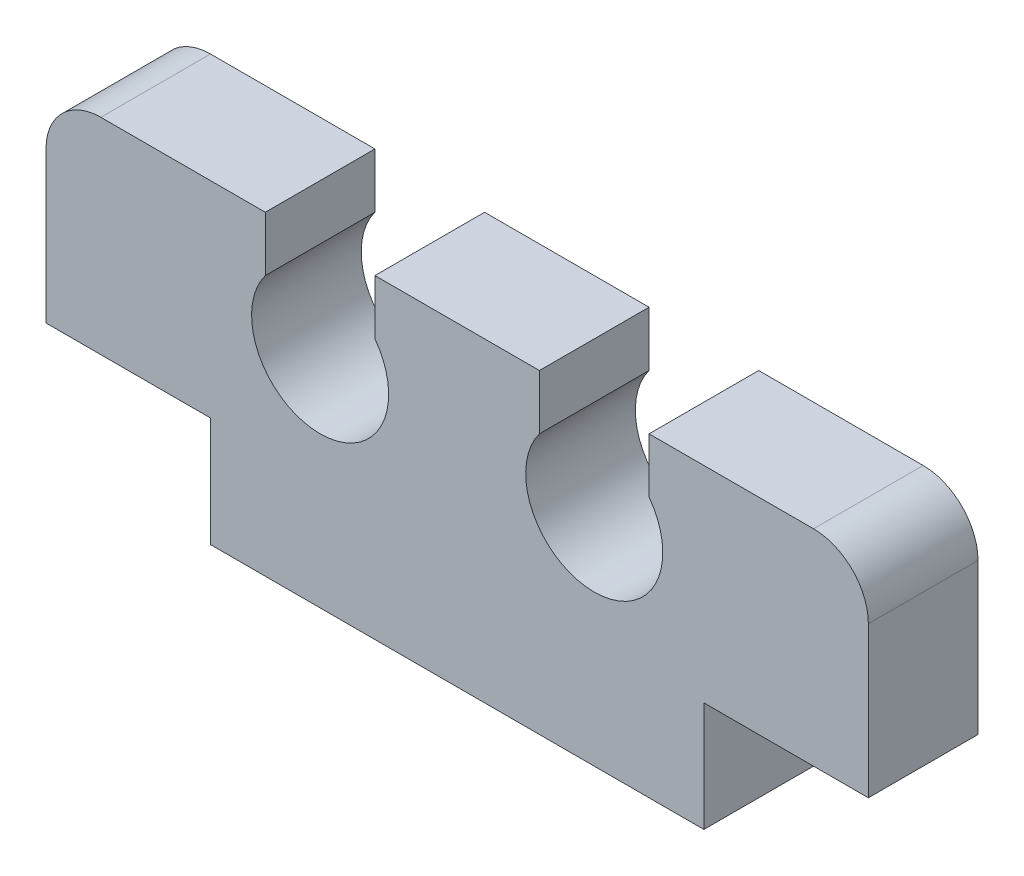
from build123d import *

# Parameters (mm, degrees)
TUBE_PLATE_MCP_BODY_DEPTH   = 2
TUBE_PLATE_MCP_CONTOURING_R = 1


with BuildPart() as part:
    # Sketch1 → Tube Plate MCP Body (new body)
    with BuildSketch(Plane.XY):
        with BuildLine():
            Line((-4.5, 0), (4.5, 0))
            Line((4.5, 0), (4.5, 2))
            Line((4.5, 2), (7.5, 2))
            Line((7.5, 2), (7.5, 5.75))
            Line((7.5, 5.75), (3.5, 5.75))
            Line((3.5, 5.75), (3.5, 4.75))
            ThreePointArc((3.5, 4.75), (2.5, 2.75), (1.5, 4.75))
            Line((1.5, 4.75), (1.5, 5.75))
            Line((1.5, 5.75), (-1.5, 5.75))
            Line((-1.5, 5.75), (-1.5, 4.75))
            ThreePointArc((-1.5, 4.75), (-2.5, 2.75), (-3.5, 4.75))
            Line((-3.5, 4.75), (-3.5, 5.75))
            Line((-3.5, 5.75), (-7.5, 5.75))
            Line((-7.5, 5.75), (-7.5, 2))
            Line((-7.5, 2), (-4.5, 2))
            Line((-4.5, 2), (-4.5, 0))
        make_face()
    extrude(amount=TUBE_PLATE_MCP_BODY_DEPTH)

    # Tube Plate MCP Contouring
    tube_plate_mcp_contouring_edges = [part.edges().sort_by_distance(p)[0] for p in [
        (-7.5, 5.75, 1),
        (7.5, 5.75, 1),
    ]]
    fillet(tube_plate_mcp_contouring_edges, radius=TUBE_PLATE_MCP_CONTOURING_R)


solid = part.part
